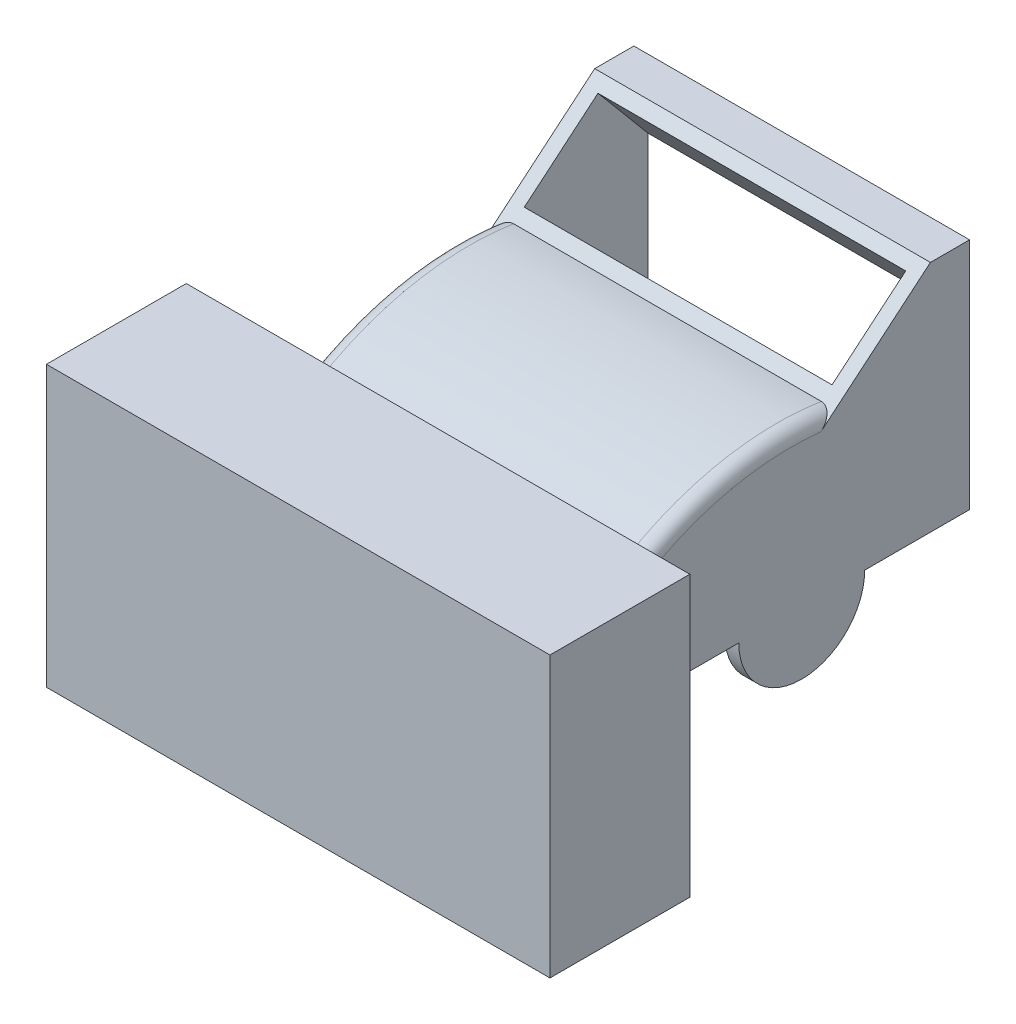
from build123d import *

# Parameters (mm, degrees)
IZIM1_W                          = 120
IZIM1_H                          = 45
Y_KSEKLIK_EKSTR_ZYON1_DEPTH      = 120
KES_EKSTR_ZYON1_DEPTH            = 120
IZIM3_W                          = 110
IZIM3_H                          = 34.383847837
KES_EKSTR_ZYON2_DEPTH            = 120
IZIM4_W                          = 109
IZIM4_H                          = 30.52938746
KES_EKSTR_ZYON3_DEPTH            = 55
KES_EKSTR_ZYON3_DEPTH_BACK       = 55
IZIM5_W                          = 94
IZIM5_H                          = 38.213938048
KES_EKSTR_ZYON4_DEPTH            = 95
IZIM6_R                          = 22.5
Y_KSEKLIK_EKSTR_ZYON2_DEPTH      = 5
IZIM7_R                          = 22.5
Y_KSEKLIK_EKSTR_ZYON3_DEPTH      = 5
RADYUS1_R                        = 5
IZIM8_W                          = 50
IZIM8_H                          = 100
Y_KSEKLIK_EKSTR_ZYON4_DEPTH      = 90
Y_KSEKLIK_EKSTR_ZYON4_DEPTH_BACK = 90


with BuildPart() as part:
    # Çizim1 → Yükseklik-Ekstrüzyon1 (new body)
    with BuildSketch(Plane.XY):
        with Locations((0, 52.5)):
            Rectangle(IZIM1_W, IZIM1_H)
        Polygon((-60, -20), (-60, 0), (-60, 30), (60, 30), (60, -20), align=None)
    extrude(amount=-Y_KSEKLIK_EKSTR_ZYON1_DEPTH)

    # Çizim2 → Kes-Ekstrüzyon1 (cut)
    with BuildSketch(Plane(origin=(60, 0, 0), x_dir=(0, 0, -1), z_dir=(1, 0, 0))):
        with BuildLine():
            Line((0, 75), (0, 20))
            ThreePointArc((0, 20), (34.643732724, 34.010082923), (72, 35))
            Line((72, 35), (106, 63.52938746))
            Line((106, 63.52938746), (120, 63.52938746))
            Line((120, 63.52938746), (120, 75))
            Line((120, 75), (0, 75))
        make_face()
    extrude(amount=-KES_EKSTR_ZYON1_DEPTH, mode=Mode.SUBTRACT)

    # Çizim3 → Kes-Ekstrüzyon2 (cut)
    with BuildSketch(Plane(origin=(0, -14.914235999, -12.514529926), x_dir=(1, 0, 0), z_dir=(0, 0.766044443, 0.64278761))):
        with Locations((0, 99.844690163)):
            Rectangle(IZIM3_W, IZIM3_H)
    extrude(amount=-KES_EKSTR_ZYON2_DEPTH, mode=Mode.SUBTRACT)

    # Çizim4 → Kes-Ekstrüzyon3 (cut, two sides)
    with BuildSketch(Plane(origin=(0, 0, 0), x_dir=(0, 0, -1), z_dir=(1, 0, 0))) as kes_ekstr_zyon3_sk:
        with Locations((60.5, 0.26469373)):
            Rectangle(IZIM4_W, IZIM4_H)
    extrude(amount=KES_EKSTR_ZYON3_DEPTH, mode=Mode.SUBTRACT)
    extrude(kes_ekstr_zyon3_sk.sketch, amount=-KES_EKSTR_ZYON3_DEPTH_BACK, mode=Mode.SUBTRACT)

    # Çizim5 → Kes-Ekstrüzyon4 (cut)
    with BuildSketch(Plane.XY.offset(-120)):
        with Locations((0, 11.106969024)):
            Rectangle(IZIM5_W, IZIM5_H)
    extrude(amount=KES_EKSTR_ZYON4_DEPTH, mode=Mode.SUBTRACT)

    # Çizim6 → Yükseklik-Ekstrüzyon2 (add)
    with BuildSketch(Plane(origin=(60, 0, 0), x_dir=(0, 0, -1), z_dir=(1, 0, 0))):
        with Locations((60, -20)):
            Circle(IZIM6_R)
    extrude(amount=-Y_KSEKLIK_EKSTR_ZYON2_DEPTH)

    # Çizim7 → Yükseklik-Ekstrüzyon3 (add)
    with BuildSketch(Plane.ZY.offset(60)):
        with Locations((-60, -20)):
            Circle(IZIM7_R)
    extrude(amount=Y_KSEKLIK_EKSTR_ZYON3_DEPTH)

    # Radyus1
    radyus1_edges = [part.edges().sort_by_distance(p)[0] for p in [
        (60, 0, 0),
        (0, 20, 0),
        (-60, 34.010082923, -34.643732724),
        (60, 34.010082923, -34.643732724),
        (-60, 0, 0),
    ]]
    fillet(radyus1_edges, radius=RADYUS1_R)


with BuildPart() as body_2:
    # Çizim8 → Yükseklik-Ekstrüzyon4 (new body, two sides)
    with BuildSketch(Plane(origin=(0, 0, 0), x_dir=(0, 0, -1), z_dir=(1, 0, 0))) as y_kseklik_ekstr_zyon4_sk:
        with Locations((-35, -10)):
            Rectangle(IZIM8_W, IZIM8_H)
    extrude(amount=Y_KSEKLIK_EKSTR_ZYON4_DEPTH)
    extrude(y_kseklik_ekstr_zyon4_sk.sketch, amount=-Y_KSEKLIK_EKSTR_ZYON4_DEPTH_BACK)


solid = Compound([part.part, body_2.part])
